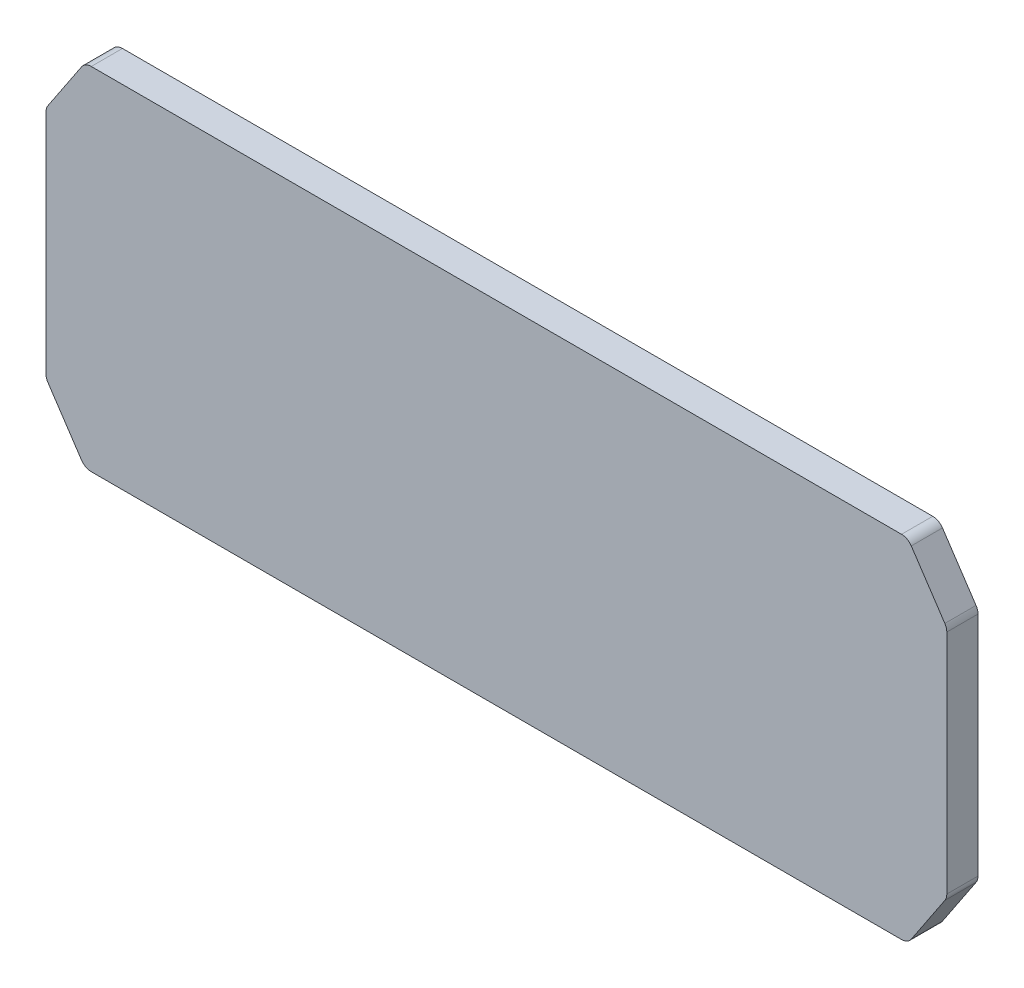
from build123d import *

# Parameters (mm, degrees)
EXTRUDE1_DEPTH = 8


with BuildPart() as part:
    # Sketch1 → Extrude1 (new body)
    with BuildSketch(Plane.XY):
        with BuildLine():
            Line((106.390599608, 1.335899411), (114.996150883, 14.244226325))
            ThreePointArc((114.996150883, 14.244226325), (115.371276079, 15.038974467), (115.5, 15.908326913))
            Line((115.5, 15.908326913), (115.5, 74.091673087))
            ThreePointArc((115.5, 74.091673087), (115.371276079, 74.961025533), (114.996150883, 75.755773675))
            Line((114.996150883, 75.755773675), (106.390599608, 88.664100589))
            ThreePointArc((106.390599608, 88.664100589), (105.310022501, 89.645023796), (103.894448725, 90))
            Line((103.894448725, 90), (-103.894448725, 90))
            ThreePointArc((-103.894448725, 90), (-105.310022501, 89.645023796), (-106.390599608, 88.664100589))
            Line((-106.390599608, 88.664100589), (-114.996150883, 75.755773675))
            ThreePointArc((-114.996150883, 75.755773675), (-115.371276079, 74.961025533), (-115.5, 74.091673087))
            Line((-115.5, 74.091673087), (-115.5, 15.908326913))
            ThreePointArc((-115.5, 15.908326913), (-115.371276079, 15.038974467), (-114.996150883, 14.244226325))
            Line((-114.996150883, 14.244226325), (-106.390599608, 1.335899411))
            ThreePointArc((-106.390599608, 1.335899411), (-105.310022501, 0.354976204), (-103.894448725, 0))
            Line((-103.894448725, 0), (103.894448725, 0))
            ThreePointArc((103.894448725, 0), (105.310022501, 0.354976204), (106.390599608, 1.335899411))
        make_face()
    extrude(amount=EXTRUDE1_DEPTH)


solid = part.part
